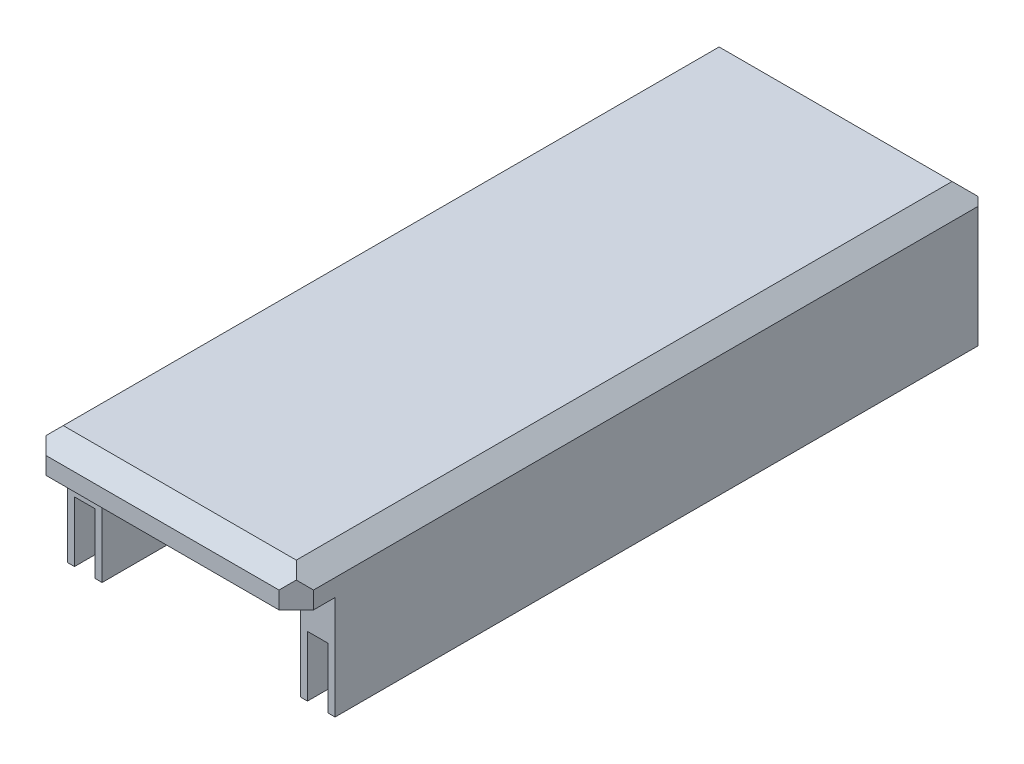
from build123d import *

# Parameters (mm, degrees)
SKETCH1_W           = 31
SKETCH1_H           = 80
BOSS_EXTRUDE1_DEPTH = 4
SKETCH2_W           = 24
SKETCH2_H           = 2.5
CUT_EXTRUDE1_DEPTH  = 3
BOSS_EXTRUDE2_DEPTH = 12
CUT_EXTRUDE3_DEPTH  = 7
SKETCH5_W           = 22.630422209
SKETCH5_H           = 4
BOSS_EXTRUDE3_DEPTH = 2
CHAMFER1_SIZE       = 2
CHAMFER2_SIZE       = 2
CHAMFER3_SIZE       = 2
CHAMFER4_SIZE       = 2
CHAMFER6_SIZE       = 1


with BuildPart() as part:
    # Sketch1 → Boss-Extrude1 (new body)
    with BuildSketch(Plane(origin=(0, 0, 0), x_dir=(1, 0, 0), z_dir=(0, 1, 0))):
        with Locations((-0.854779412, 28.517463235)):
            Rectangle(SKETCH1_W, SKETCH1_H)
    extrude(amount=BOSS_EXTRUDE1_DEPTH)

    # Sketch2 → Cut-Extrude1 (cut)
    with BuildSketch(Plane.XZ):
        with Locations((-0.854779412, 8.232536765)):
            Rectangle(SKETCH2_W, SKETCH2_H)
    extrude(amount=-CUT_EXTRUDE1_DEPTH, mode=Mode.SUBTRACT)

    # Sketch3 → Boss-Extrude2 (add)
    with BuildSketch(Plane.XZ):
        Polygon((-16.354779412, 6.982536765), (-12.354779412, 6.982536765), (-12.354779412, -64.517463235), (10.645220588, -64.517463235), (10.645220588, 6.982536765), (14.645220588, 6.982536765), (14.645220588, -68.517463235), (10.645220588, -68.517463235), (-12.354779412, -68.517463235), (-16.354779412, -68.517463235), align=None)
    extrude(amount=BOSS_EXTRUDE2_DEPTH)

    # Sketch4 → Cut-Extrude3 (cut)
    with BuildSketch(Plane.XZ.offset(12)):
        Polygon((-15.554779412, 6.982536765), (-13.154779412, 6.982536765), (-13.154779412, -65.317463235), (-12.154779412, -65.317463235), (-12.154779412, -67.717463235), (-13.154779412, -67.717463235), (-15.554779412, -67.717463235), align=None)
        Polygon((11.445220588, 6.982536765), (13.845220588, 6.982536765), (13.845220588, -67.717463235), (11.445220588, -67.717463235), (10.445220588, -67.717463235), (10.445220588, -65.317463235), (11.445220588, -65.317463235), align=None)
    extrude(amount=-CUT_EXTRUDE3_DEPTH, mode=Mode.SUBTRACT)

    # Sketch5 → Boss-Extrude3 (add)
    with BuildSketch(Plane.XZ.offset(12)):
        with Locations((-0.839568307, -66.517463235)):
            Rectangle(SKETCH5_W, SKETCH5_H)
    extrude(amount=BOSS_EXTRUDE3_DEPTH)

    # Chamfer1
    chamfer1_edges = [part.edges().sort_by_distance(p)[0] for p in [
        (-16.354779412, 2, 11.482536765),
        (14.645220588, 2, 11.482536765),
    ]]
    chamfer(chamfer1_edges, length=CHAMFER1_SIZE)

    # Chamfer2
    chamfer2_edges = [part.edges().sort_by_distance(p)[0] for p in [
        (-0.854779412, 4, 11.482536765),
    ]]
    chamfer(chamfer2_edges, length=CHAMFER2_SIZE)

    # Chamfer3
    chamfer3_edges = [part.edges().sort_by_distance(p)[0] for p in [
        (-16.354779412, 4, -29.517463235),
        (14.645220588, 4, -29.517463235),
    ]]
    chamfer(chamfer3_edges, length=CHAMFER3_SIZE)

    # Chamfer4
    chamfer4_edges = [part.edges().sort_by_distance(p)[0] for p in [
        (-0.854779412, 4, -68.517463235),
    ]]
    chamfer(chamfer4_edges, length=CHAMFER4_SIZE)

    # Chamfer6
    chamfer6_edges = [part.edges().sort_by_distance(p)[0] for p in [
        (14.645220588, -5, -68.517463235),
        (-16.354779412, -5, -68.517463235),
    ]]
    chamfer(chamfer6_edges, length=CHAMFER6_SIZE)


solid = part.part
